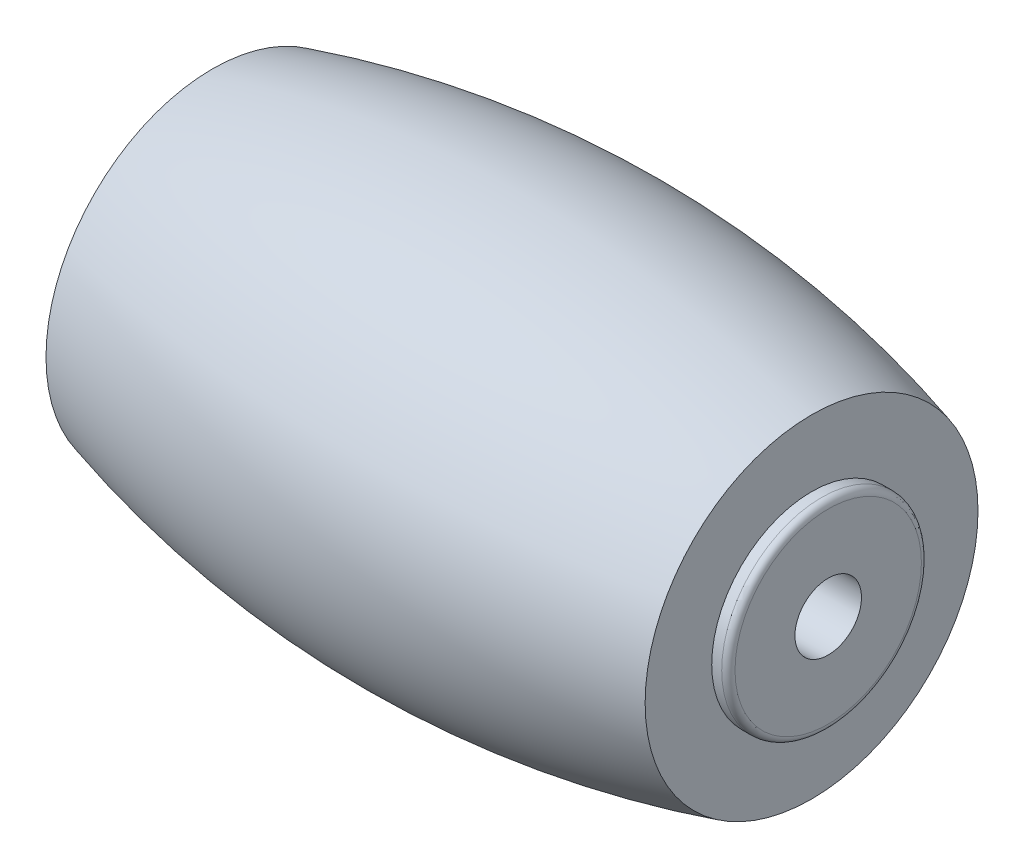
from build123d import *

# Parameters (mm, degrees)
SKETCH3_R           = 3
BOSS_EXTRUDE1_DEPTH = 0.5
SKETCH4_R           = 1
CUT_EXTRUDE2_DEPTH  = 20
FILLET1_R           = 0.2


with BuildPart() as part:
    # Sketch1 → Revolve1 (revolve)
    with BuildSketch(Plane(origin=(0, 0, 0), x_dir=(1, 0, 0), z_dir=(0, 1, 0))):
        with BuildLine():
            Line((0, 0), (-9, 0))
            Line((-9, 0), (-9, 5))
            ThreePointArc((-9, 5), (0, 6.249672879), (9, 5))
            Line((9, 5), (9, 0))
            Line((9, 0), (0, 0))
        make_face()
    revolve(axis=Axis((0, 0, 0), (-1, 0, 0)))

    # Sketch3 → Boss-Extrude1 (add)
    with BuildSketch(Plane(origin=(9, 0, 0), x_dir=(0, 0, -1), z_dir=(1, 0, 0))):
        Circle(SKETCH3_R)
    boss_extrude1 = extrude(amount=BOSS_EXTRUDE1_DEPTH)

    # Mirror1: Boss-Extrude1 across plane
    add(boss_extrude1.mirror(Plane(origin=(0, 0, 0), x_dir=(0, 0, 1), z_dir=(1, 0, 0))))

    # Sketch4 → Cut-Extrude2 (cut, through all)
    with BuildSketch(Plane.ZY.offset(9.5)):
        Circle(SKETCH4_R)
    extrude(amount=-CUT_EXTRUDE2_DEPTH, mode=Mode.SUBTRACT)

    # Fillet1
    fillet1_edges = [part.edges().sort_by_distance(p)[0] for p in [
        (9.5, 0, 3),
        (-9.5, 0, 3),
    ]]
    fillet(fillet1_edges, radius=FILLET1_R)


solid = part.part
